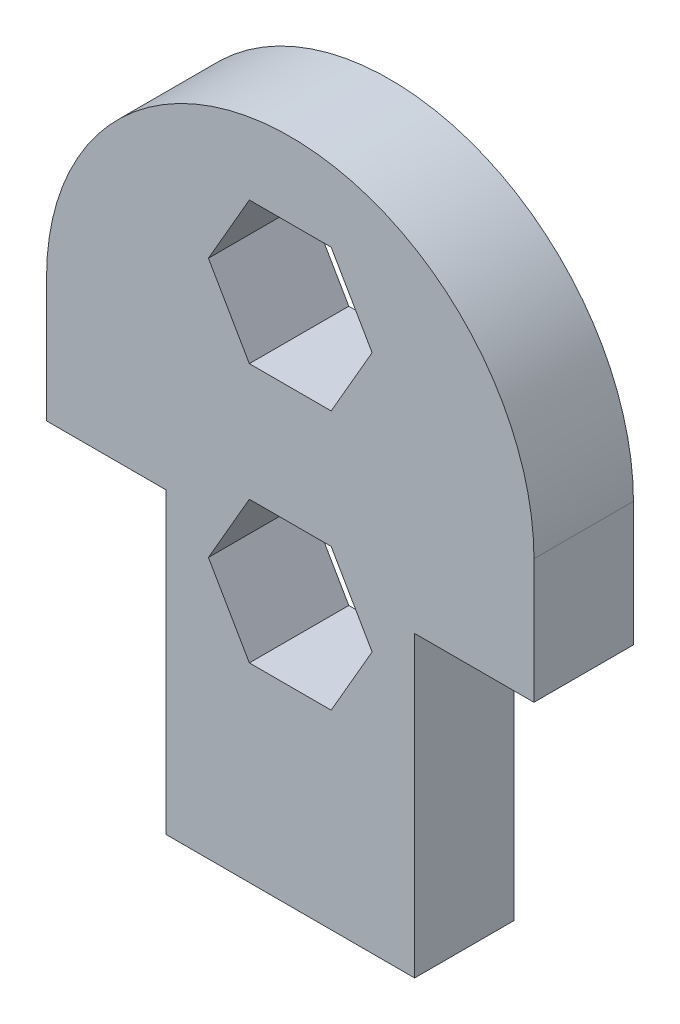
from build123d import *

# Parameters (mm, degrees)
BOSS_EXTRUDE1_DEPTH = 4
SKETCH2_W           = 2.5
SKETCH2_H           = 4
CUT_EXTRUDE1_DEPTH  = 4


with BuildPart() as part:
    # Sketch1 → Boss-Extrude1 (new body)
    with BuildSketch(Plane.XY):
        with BuildLine():
            Line((0, 0), (10, 0))
            Line((10, 0), (10, 4))
            Line((10, 4), (12.5, 4))
            Line((12.5, 4), (12.5, 8))
            Line((12.5, 8), (10, 8))
            Line((10, 8), (10, 12))
            Line((10, 12), (14.8, 12))
            Line((14.8, 12), (14.8, 17))
            ThreePointArc((14.8, 17), (5, 26.8), (-4.8, 17))
            Line((-4.8, 17), (-4.8, 12))
            Line((-4.8, 12), (0, 12))
            Line((0, 12), (0, 8))
            Line((0, 8), (-2.5, 8))
            Line((-2.5, 8), (-2.5, 4))
            Line((-2.5, 4), (0, 4))
            Line((0, 4), (0, 0))
        make_face()
        Polygon((3.354551733, 18.071172359), (6.645448267, 18.071172359), (8.290896534, 20.921172359), (6.645448267, 23.771172359), (3.354551733, 23.771172359), (1.709103466, 20.921172359), align=None, mode=Mode.SUBTRACT)
        Polygon((8.290896534, 10.5), (6.645448267, 13.35), (3.354551733, 13.35), (1.709103466, 10.5), (3.354551733, 7.65), (6.645448267, 7.65), align=None, mode=Mode.SUBTRACT)
    extrude(amount=BOSS_EXTRUDE1_DEPTH)

    # Sketch2 → Cut-Extrude1 (cut)
    with BuildSketch(Plane.XY.offset(4)):
        with Locations((-1.25, 6)):
            Rectangle(SKETCH2_W, SKETCH2_H)
        with Locations((11.25, 6)):
            Rectangle(SKETCH2_W, SKETCH2_H)
    extrude(amount=-CUT_EXTRUDE1_DEPTH, mode=Mode.SUBTRACT)


solid = part.part
